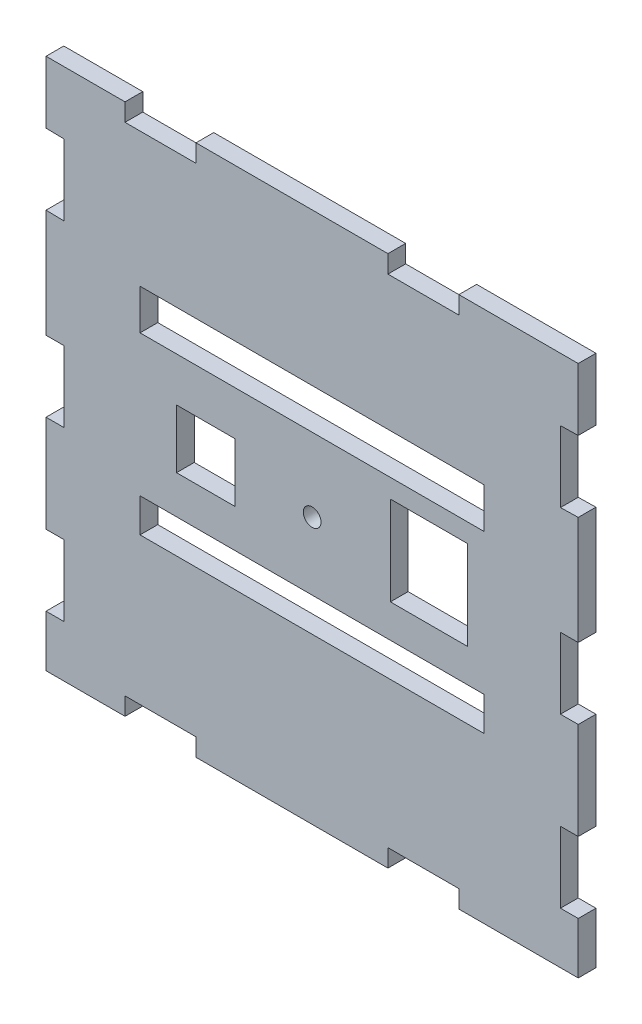
from build123d import *

# Parameters (mm, degrees)
SKETCH1_R           = 2.5
SKETCH1_W           = 97.010301716
SKETCH1_H           = 11.381096849
SKETCH1_H_2         = 9.548114026
SKETCH1_W_2         = 16.423850042
SKETCH1_H_3         = 16.534248646
SKETCH1_W_3         = 21.691877415
SKETCH1_H_4         = 25.100601008
BOSS_EXTRUDE1_DEPTH = 5


with BuildPart() as part:
    # Sketch1 → Boss-Extrude1 (new body)
    with BuildSketch(Plane.XY):
        Polygon((-75, -75), (-52.738744268, -75), (-52.738744268, -70), (-32.738744268, -70), (-32.738744268, -75), (21.360897281, -75), (21.360897281, -70), (41.360897281, -70), (41.360897281, -75), (75, -75), (75, -60.464153422), (70, -60.464153422), (70, -40.464153422), (75, -40.464153422), (75, -13.109084485), (70, -13.109084485), (70, 6.890915515), (75, 6.890915515), (75, 37.435704121), (70.001007164, 37.335351613), (70.001007164, 57.335351613), (75, 57.435704121), (75, 75), (41.360897281, 75), (41.360897281, 70), (21.360897281, 70), (21.360897281, 75), (-32.738744268, 75), (-32.738744268, 70), (-52.738744268, 70), (-52.738744268, 75), (-75, 75), (-75, 57.435704121), (-70.001007164, 57.335351613), (-70.001007164, 37.335351613), (-75, 37.435704121), (-75, 6.890915515), (-70, 6.890915515), (-70, -13.109084485), (-75, -13.109084485), (-75, -40.464153422), (-70, -40.464153422), (-70, -60.464153422), (-75, -60.464153422), align=None)
        Circle(SKETCH1_R, mode=Mode.SUBTRACT)
        with Locations((0, 26.4204034)):
            Rectangle(SKETCH1_W, SKETCH1_H, mode=Mode.SUBTRACT)
        with Locations((0, -23.814174359)):
            Rectangle(SKETCH1_W, SKETCH1_H_2, mode=Mode.SUBTRACT)
        with Locations((-30.010920628, 0)):
            Rectangle(SKETCH1_W_2, SKETCH1_H_3, mode=Mode.SUBTRACT)
        with Locations((32.895523873, 2.888698347)):
            Rectangle(SKETCH1_W_3, SKETCH1_H_4, mode=Mode.SUBTRACT)
    extrude(amount=BOSS_EXTRUDE1_DEPTH)


solid = part.part
